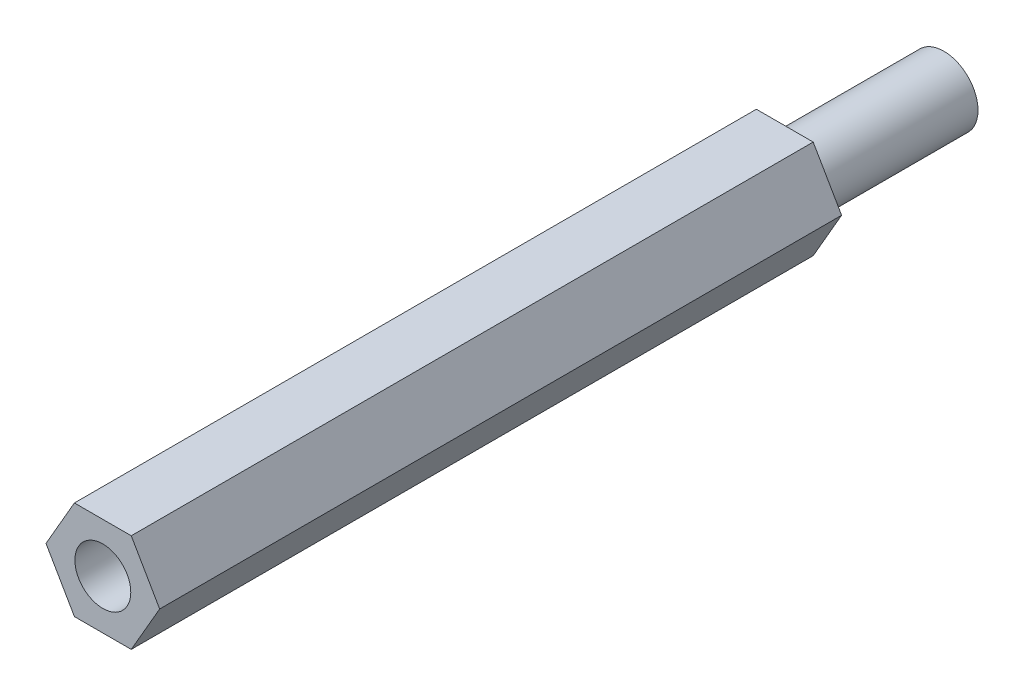
from build123d import *

# Parameters (mm, degrees)
ESTRUSIONE_ESTRUSIONE1_DEPTH = 30
SCHIZZO2_R                   = 1.5
ESTRUSIONE_ESTRUSIONE2_DEPTH = 7
FORO1_D                      = 2.459
FORO1_DEPTH                  = 7


with BuildPart() as part:
    # Schizzo1 → Estrusione-Estrusione1 (new body)
    with BuildSketch(Plane.XY):
        Polygon((1.25, -2.165063509), (2.5, 0), (1.25, 2.165063509), (-1.25, 2.165063509), (-2.5, 0), (-1.25, -2.165063509), align=None)
    extrude(amount=-ESTRUSIONE_ESTRUSIONE1_DEPTH)

    # Schizzo2 → Estrusione-Estrusione2 (add)
    with BuildSketch(Plane(origin=(0, 0, -30), x_dir=(-1, 0, 0), z_dir=(0, 0, -1))):
        Circle(SCHIZZO2_R)
    extrude(amount=ESTRUSIONE_ESTRUSIONE2_DEPTH)

    # Foro1
    with Locations(Plane.XY):
        with Locations((0, 0)):
            Hole(FORO1_D / 2, depth=FORO1_DEPTH)


solid = part.part
